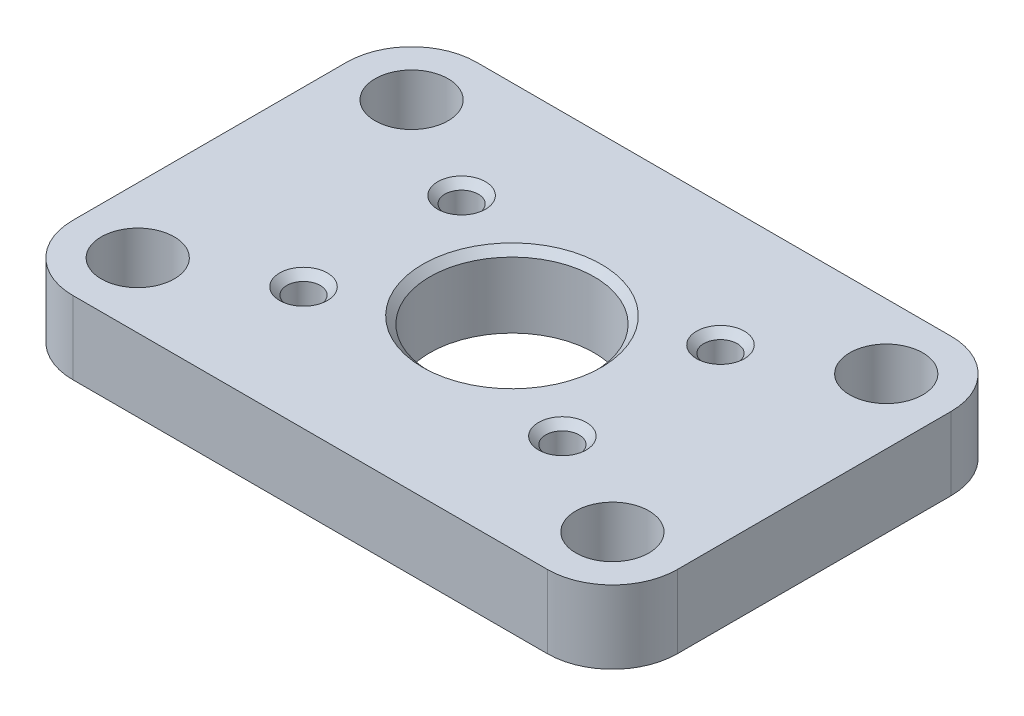
from build123d import *

# Parameters (mm, degrees)
SKETCH1_R           = 2.54
BOSS_EXTRUDE1_DEPTH = 5.08
SKETCH3_R           = 1.16205
SKETCH3_R_2         = 5.715
CUT_EXTRUDE4_DEPTH  = 6.08
CHAMFER1_SIZE       = 0.5


with BuildPart() as part:
    # Sketch1 → Boss-Extrude1 (new body)
    with BuildSketch(Plane(origin=(0, 0, 0), x_dir=(1, 0, 0), z_dir=(0, 1, 0))):
        with BuildLine():
            Line((-16.51, -14.0462), (16.51, -14.0462))
            ThreePointArc((16.51, -14.0462), (19.706971179, -12.721971179), (21.0312, -9.525))
            Line((21.0312, -9.525), (21.0312, 9.525))
            ThreePointArc((21.0312, 9.525), (19.706971179, 12.721971179), (16.51, 14.0462))
            Line((16.51, 14.0462), (-16.51, 14.0462))
            ThreePointArc((-16.51, 14.0462), (-19.706971179, 12.721971179), (-21.0312, 9.525))
            Line((-21.0312, 9.525), (-21.0312, -9.525))
            ThreePointArc((-21.0312, -9.525), (-19.706971179, -12.721971179), (-16.51, -14.0462))
        make_face()
        with Locations((-16.51, 9.525)):
            Circle(SKETCH1_R, mode=Mode.SUBTRACT)
        with Locations((-16.51, -9.525)):
            Circle(SKETCH1_R, mode=Mode.SUBTRACT)
        with Locations((16.51, -9.525)):
            Circle(SKETCH1_R, mode=Mode.SUBTRACT)
        with Locations((16.51, 9.525)):
            Circle(SKETCH1_R, mode=Mode.SUBTRACT)
    extrude(amount=BOSS_EXTRUDE1_DEPTH)

    # Sketch3 → Cut-Extrude4 (cut, through all)
    with BuildSketch(Plane(origin=(0, 5.08, 0), x_dir=(1, 0, 0), z_dir=(0, 1, 0))):
        with Locations((-9.0043, 5.4991)):
            Circle(SKETCH3_R)
        with Locations((9.0043, 5.4991)):
            Circle(SKETCH3_R)
        with Locations((9.0043, -5.4991)):
            Circle(SKETCH3_R)
        with Locations((-9.0043, -5.4991)):
            Circle(SKETCH3_R)
        Circle(SKETCH3_R_2)
    extrude(amount=-CUT_EXTRUDE4_DEPTH, mode=Mode.SUBTRACT)

    # Chamfer1
    chamfer1_edges = [part.edges().sort_by_distance(p)[0] for p in [
        (-5.715, 5.08, 0),
        (-10.16635, 5.08, 5.4991),
        (7.84225, 5.08, 5.4991),
        (7.84225, 5.08, -5.4991),
        (-10.16635, 5.08, -5.4991),
    ]]
    chamfer(chamfer1_edges, length=CHAMFER1_SIZE)


solid = part.part
